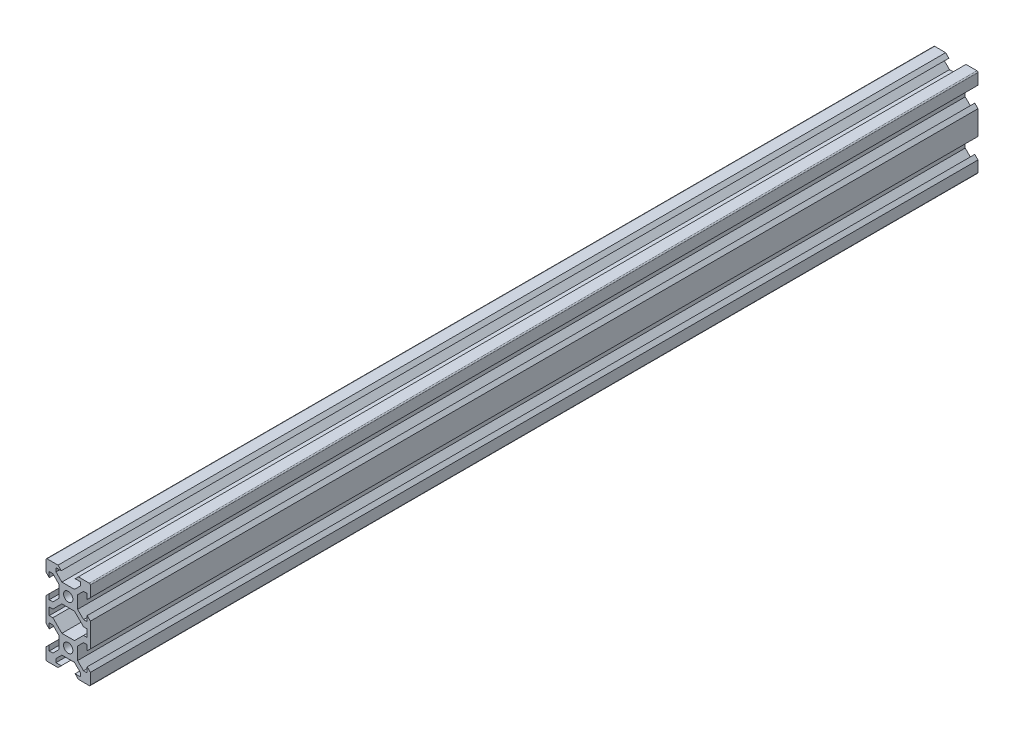
from build123d import *

# Parameters (mm, degrees)
SKETCH2_R           = 2.1
BOSS_EXTRUDE1_DEPTH = 400


with BuildPart() as part:
    # Sketch2 → Boss-Extrude1 (new body)
    with BuildSketch(Plane.XY):
        with BuildLine():
            Line((-10, 15.42), (-10, 10))
            Line((-10, 10), (-8.545, 10))
            Line((-8.545, 10), (-8.545, 11.69))
            Line((-8.545, 11.69), (-6.905, 11.69))
            Line((-6.905, 11.69), (-2.84, 15.755))
            Line((-2.84, 15.755), (2.84, 15.755))
            Line((2.84, 15.755), (6.905, 11.69))
            Line((6.905, 11.69), (8.545, 11.69))
            Line((8.545, 11.69), (8.545, 10))
            Line((8.545, 10), (10, 10))
            Line((10, 10), (10, 15.42))
            Line((10, 15.42), (8.545, 16.875))
            Line((8.545, 16.875), (8.545, 14.5))
            Line((8.545, 14.5), (6.905, 14.5))
            Line((6.905, 14.5), (4.245, 17.16))
            Line((4.245, 17.16), (4.245, 22.84))
            Line((4.245, 22.84), (6.905, 25.5))
            Line((6.905, 25.5), (8.545, 25.5))
            Line((8.545, 25.5), (8.545, 23.125))
            Line((8.545, 23.125), (10, 24.58))
            Line((10, 24.58), (10, 29.5))
            ThreePointArc((10, 29.5), (9.853553391, 29.853553391), (9.5, 30))
            Line((9.5, 30), (4.58, 30))
            Line((4.58, 30), (3.125, 28.545))
            Line((3.125, 28.545), (5.5, 28.545))
            Line((5.5, 28.545), (5.5, 26.905))
            Line((5.5, 26.905), (2.84, 24.245))
            Line((2.84, 24.245), (-2.84, 24.245))
            Line((-2.84, 24.245), (-5.5, 26.905))
            Line((-5.5, 26.905), (-5.5, 28.545))
            Line((-5.5, 28.545), (-3.125, 28.545))
            Line((-3.125, 28.545), (-4.58, 30))
            Line((-4.58, 30), (-9.5, 30))
            ThreePointArc((-9.5, 30), (-9.853553391, 29.853553391), (-10, 29.5))
            Line((-10, 29.5), (-10, 24.58))
            Line((-10, 24.58), (-8.545, 23.125))
            Line((-8.545, 23.125), (-8.545, 25.5))
            Line((-8.545, 25.5), (-6.905, 25.5))
            Line((-6.905, 25.5), (-4.245, 22.84))
            Line((-4.245, 22.84), (-4.245, 17.16))
            Line((-4.245, 17.16), (-6.905, 14.5))
            Line((-6.905, 14.5), (-8.545, 14.5))
            Line((-8.545, 14.5), (-8.545, 16.875))
            Line((-8.545, 16.875), (-10, 15.42))
        make_face()
        with Locations((0, 20)):
            Circle(SKETCH2_R, mode=Mode.SUBTRACT)
        with BuildLine():
            Line((-9.5, -10), (-4.58, -10))
            Line((-4.58, -10), (-3.125, -8.545))
            Line((-3.125, -8.545), (-5.5, -8.545))
            Line((-5.5, -8.545), (-5.5, -6.905))
            Line((-5.5, -6.905), (-2.84, -4.245))
            Line((-2.84, -4.245), (2.84, -4.245))
            Line((2.84, -4.245), (5.5, -6.905))
            Line((5.5, -6.905), (5.5, -8.545))
            Line((5.5, -8.545), (3.125, -8.545))
            Line((3.125, -8.545), (4.58, -10))
            Line((4.58, -10), (9.5, -10))
            ThreePointArc((9.5, -10), (9.853553391, -9.853553391), (10, -9.5))
            Line((10, -9.5), (10, -4.58))
            Line((10, -4.58), (8.545, -3.125))
            Line((8.545, -3.125), (8.545, -5.5))
            Line((8.545, -5.5), (6.905, -5.5))
            Line((6.905, -5.5), (4.245, -2.84))
            Line((4.245, -2.84), (4.245, 2.84))
            Line((4.245, 2.84), (6.905, 5.5))
            Line((6.905, 5.5), (8.545, 5.5))
            Line((8.545, 5.5), (8.545, 3.125))
            Line((8.545, 3.125), (10, 4.58))
            Line((10, 4.58), (10, 10))
            Line((10, 10), (8.545, 10))
            Line((8.545, 10), (8.545, 8.31))
            Line((8.545, 8.31), (6.905, 8.31))
            Line((6.905, 8.31), (2.84, 4.245))
            Line((2.84, 4.245), (-2.84, 4.245))
            Line((-2.84, 4.245), (-6.905, 8.31))
            Line((-6.905, 8.31), (-8.545, 8.31))
            Line((-8.545, 8.31), (-8.545, 10))
            Line((-8.545, 10), (-10, 10))
            Line((-10, 10), (-10, 4.58))
            Line((-10, 4.58), (-8.545, 3.125))
            Line((-8.545, 3.125), (-8.545, 5.5))
            Line((-8.545, 5.5), (-6.905, 5.5))
            Line((-6.905, 5.5), (-4.245, 2.84))
            Line((-4.245, 2.84), (-4.245, -2.84))
            Line((-4.245, -2.84), (-6.905, -5.5))
            Line((-6.905, -5.5), (-8.545, -5.5))
            Line((-8.545, -5.5), (-8.545, -3.125))
            Line((-8.545, -3.125), (-10, -4.58))
            Line((-10, -4.58), (-10, -9.5))
            ThreePointArc((-10, -9.5), (-9.853553391, -9.853553391), (-9.5, -10))
        make_face()
        Circle(SKETCH2_R, mode=Mode.SUBTRACT)
    extrude(amount=BOSS_EXTRUDE1_DEPTH)


solid = part.part
